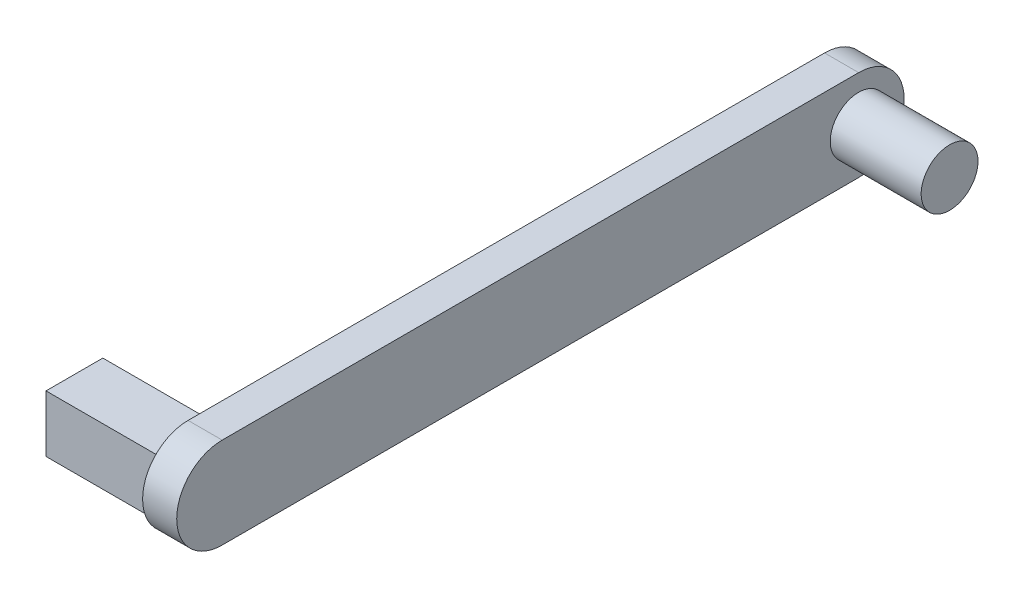
from build123d import *

# Parameters (mm, degrees)
SKETCH1_R           = 3.81
BOSS_EXTRUDE1_DEPTH = 3.048
BOSS_EXTRUDE5_DEPTH = 3.81
SKETCH5_R           = 3.175
BOSS_EXTRUDE6_DEPTH = 10.16
SKETCH6_W           = 6.35
SKETCH6_H           = 6.35
BOSS_EXTRUDE7_DEPTH = 12.7


with BuildPart() as part:
    # Sketch1 → Boss-Extrude1 (new body)
    with BuildSketch(Plane(origin=(0, 0, 0), x_dir=(0, 0, -1), z_dir=(1, 0, 0))):
        Circle(SKETCH1_R)
    extrude(amount=BOSS_EXTRUDE1_DEPTH)

    # Sketch4 → Boss-Extrude5 (add)
    with BuildSketch(Plane(origin=(3.048, 0, 0), x_dir=(0, 0, -1), z_dir=(1, 0, 0))):
        with BuildLine():
            Line((0, 5.08), (71.12, 5.08))
            ThreePointArc((71.12, 5.08), (76.2, 0), (71.12, -5.08))
            Line((71.12, -5.08), (0, -5.08))
            ThreePointArc((0, -5.08), (-5.08, 0), (0, 5.08))
        make_face()
    extrude(amount=-BOSS_EXTRUDE5_DEPTH)

    # Sketch5 → Boss-Extrude6 (add)
    with BuildSketch(Plane(origin=(3.048, 0, 0), x_dir=(0, 0, -1), z_dir=(1, 0, 0))):
        with Locations((71.12, 0)):
            Circle(SKETCH5_R)
    extrude(amount=BOSS_EXTRUDE6_DEPTH)

    # Sketch6 → Boss-Extrude7 (add)
    with BuildSketch(Plane.ZY.offset(0.762)):
        Rectangle(SKETCH6_W, SKETCH6_H)
    extrude(amount=BOSS_EXTRUDE7_DEPTH)


solid = part.part
